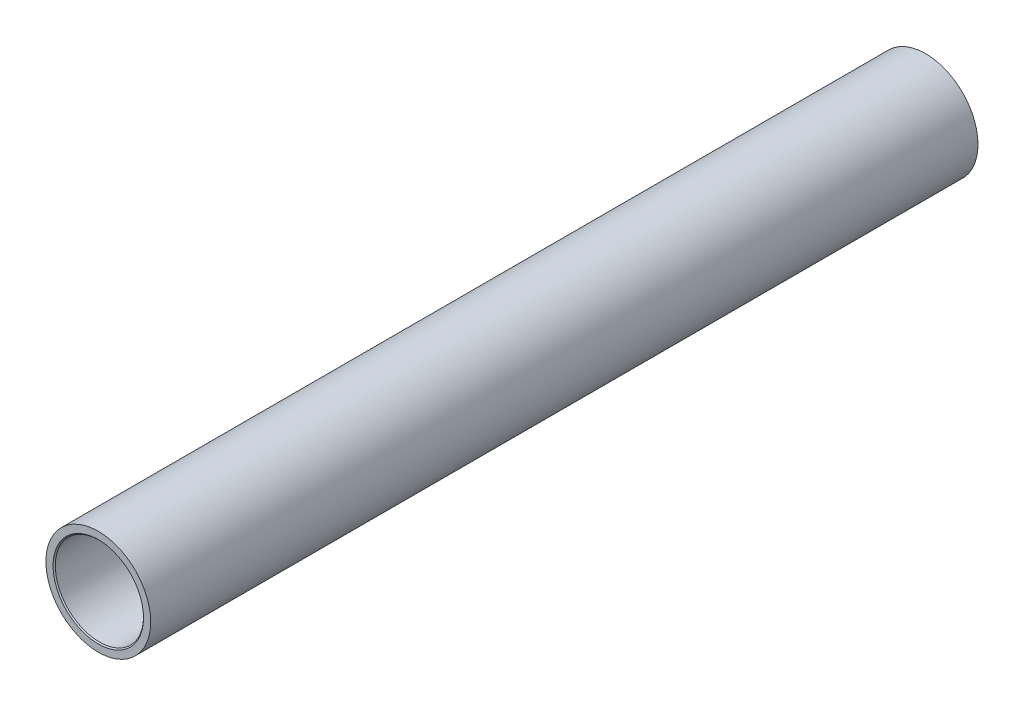
from build123d import *

# Parameters (mm, degrees)
SKETCH1_R           = 47.5
SKETCH1_R_2         = 40
BOSS_EXTRUDE1_DEPTH = 375
CUT_EXTRUDE1_DEPTH  = 20
SKETCH3_R           = 10
SKETCH3_R_2         = 5
BOSS_EXTRUDE2_DEPTH = 5
BOSS_EXTRUDE3_REACH = 391.752
SKETCH4_R           = 10
SKETCH4_R_2         = 5
CHAMFER1_SIZE       = 1


with BuildPart() as part:
    # Sketch1 → Boss-Extrude1 (new, symmetric)
    with BuildSketch(Plane.XY):
        Circle(SKETCH1_R)
        Circle(SKETCH1_R_2, mode=Mode.SUBTRACT)
    extrude(amount=BOSS_EXTRUDE1_DEPTH, both=True)

    # Sketch2 → Cut-Extrude1 (cut)
    with BuildSketch(Plane(origin=(0, -47.5, 0), x_dir=(-1, 0, 0), z_dir=(0, -1, 0))):
        with BuildLine():
            ThreePointArc((5, 342), (3.535533906, 345.535533906), (0, 347))
            Line((0, 347), (0, 342))
            Line((0, 342), (0, 337))
            ThreePointArc((0, 337), (3.535533906, 338.464466094), (5, 342))
        make_face()
        with BuildLine():
            Line((0, 342), (0, 347))
            ThreePointArc((0, 347), (-5, 342), (0, 337))
            Line((0, 337), (0, 342))
        make_face()
    extrude(amount=-CUT_EXTRUDE1_DEPTH, mode=Mode.SUBTRACT)


with BuildPart() as body_2:
    # Sketch3 → Boss-Extrude2 (new body)
    with BuildSketch(Plane(origin=(0, -47.5, 0), x_dir=(-1, 0, 0), z_dir=(0, -1, 0))):
        with Locations(Location((0, 342, 0), (0, 0, 90))):
            Circle(SKETCH3_R)
        with Locations(Location((0, 342, 0), (0, 0, 90))):
            Circle(SKETCH3_R_2, mode=Mode.SUBTRACT)
    extrude(amount=BOSS_EXTRUDE2_DEPTH)


with BuildPart() as body_3:

    # Sketch4 → Boss-Extrude3 (new, up to next)
    with BuildSketch(Plane(origin=(0, -47.5, 0), x_dir=(-1, 0, 0), z_dir=(0, -1, 0)), mode=Mode.PRIVATE) as boss_extrude3_sk1:
        with Locations(Location((0, 342, 0), (0, 0, 90))):
            Circle(SKETCH4_R)
        with Locations(Location((0, 342, 0), (0, 0, 90))):
            Circle(SKETCH4_R_2, mode=Mode.SUBTRACT)
    boss_extrude3_tool1 = extrude(boss_extrude3_sk1.sketch, amount=-BOSS_EXTRUDE3_REACH, mode=Mode.PRIVATE) - part.part
    add(boss_extrude3_tool1.solids().sort_by_distance((0, -47.5, -332.282843))[0])
    add(boss_extrude3_tool1.solids().sort_by_distance((0, -47.5, -332.282843))[1])


with BuildPart() as part_1:
    add(part.part)

    # Chamfer1
    chamfer1_edges = [part_1.edges().sort_by_distance(p)[0] for p in [
        (-40, 0, -375),
        (-40, 0, 375),
    ]]
    chamfer(chamfer1_edges, length=CHAMFER1_SIZE)


solid = Compound([body_2.part, body_3.part, part_1.part])
